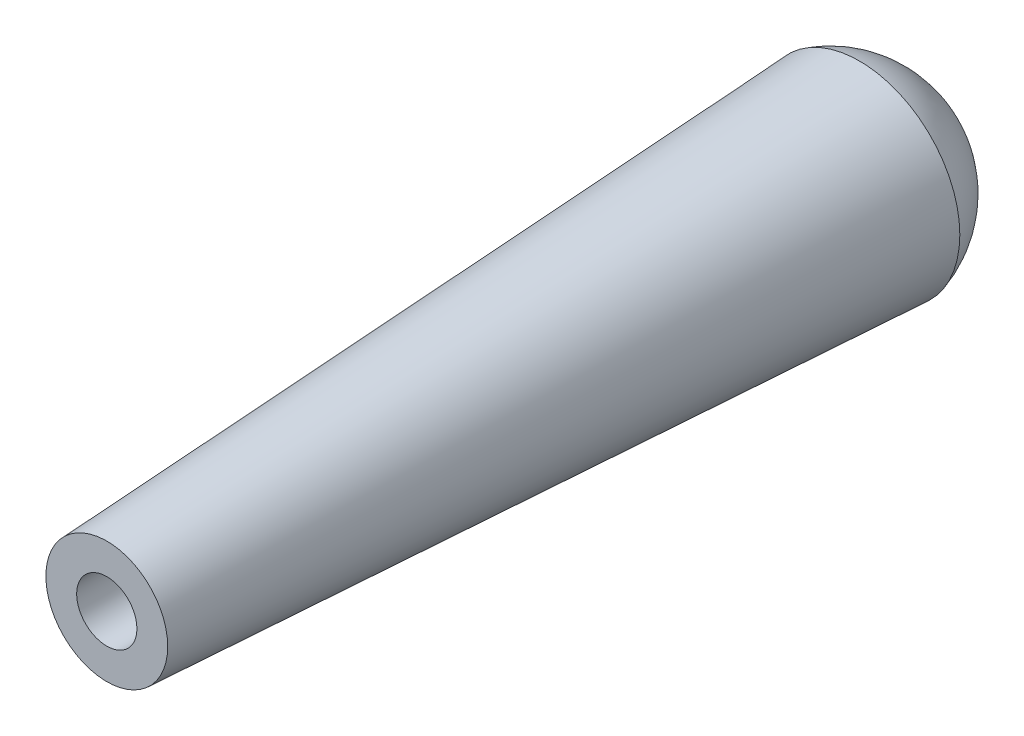
from build123d import *

# Parameters (mm, degrees)
SKETCH1_R           = 50.8
BOSS_EXTRUDE1_DEPTH = 381
BOSS_EXTRUDE1_TAPER = 3
DOME1_FACE_RADIUS   = 50.8
DOME1_HEIGHT        = 38.1
SKETCH5_R           = 15.24
CUT_EXTRUDE1_DEPTH  = 254


with BuildPart() as part:
    # Sketch1 → Boss-Extrude1 (new body)
    with BuildSketch(Plane.XY):
        Circle(SKETCH1_R)
    extrude(amount=BOSS_EXTRUDE1_DEPTH, taper=BOSS_EXTRUDE1_TAPER)

    # Dome1: a dome of height H over a round flat face of radius A is a cap of a sphere of radius (A * A + H * H) / (2 * H)
    dome1_r = (DOME1_FACE_RADIUS * DOME1_FACE_RADIUS + DOME1_HEIGHT * DOME1_HEIGHT) / (2 * DOME1_HEIGHT)
    dome1_base = Plane((0, 0, 0), z_dir=(0, 0, -1))
    with Locations(dome1_base.offset(DOME1_HEIGHT - dome1_r)):
        dome1_ball = Sphere(dome1_r, mode=Mode.PRIVATE)
    add(split(dome1_ball, bisect_by=dome1_base, keep=Keep.TOP, mode=Mode.PRIVATE))

    # Sketch5 → Cut-Extrude1 (cut)
    with BuildSketch(Plane.XY.offset(381)):
        Circle(SKETCH5_R)
    extrude(amount=-CUT_EXTRUDE1_DEPTH, mode=Mode.SUBTRACT)


solid = part.part
